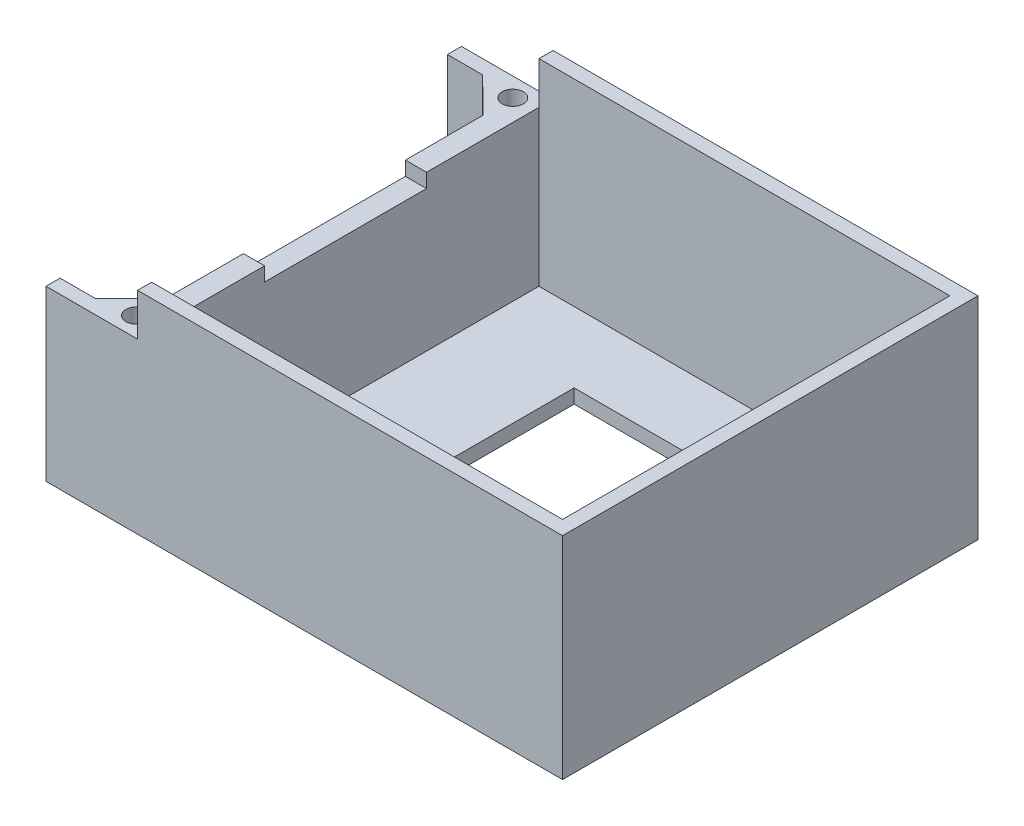
from build123d import *

# Parameters (mm, degrees)
SKETCH1_W           = 70
SKETCH1_H           = 55
BOSS_EXTRUDE1_DEPTH = 2
SKETCH2_W           = 73.35025282
SKETCH2_H           = 59
BOSS_EXTRUDE3_DEPTH = 2
BOSS_EXTRUDE4_DEPTH = 28
BOSS_EXTRUDE5_DEPTH = 22
SKETCH14_W          = 13
SKETCH14_H          = 2
CUT_EXTRUDE5_DEPTH  = 6
SKETCH15_R          = 1.5
CUT_EXTRUDE6_DEPTH  = 25
SKETCH16_R          = 2.25
CUT_EXTRUDE7_DEPTH  = 21
SKETCH17_W          = 3
SKETCH17_H          = 23
CUT_EXTRUDE8_DEPTH  = 2
SKETCH18_W          = 37
SKETCH18_H          = 35
CUT_EXTRUDE9_DEPTH  = 3
CUT_EXTRUDE12_DEPTH = 1


with BuildPart() as part:
    # Sketch1 → Boss-Extrude1 (new body)
    with BuildSketch(Plane(origin=(0, 0, 0), x_dir=(1, 0, 0), z_dir=(0, 1, 0))):
        with Locations((35, -27.5)):
            Rectangle(SKETCH1_W, SKETCH1_H)
    extrude(amount=BOSS_EXTRUDE1_DEPTH)

    # Sketch2 → Boss-Extrude3 (add)
    with BuildSketch(Plane(origin=(0, 0, 0), x_dir=(1, 0, 0), z_dir=(0, 1, 0))):
        with Locations((35.32487359, -27.5)):
            Rectangle(SKETCH2_W, SKETCH2_H)
    extrude(amount=BOSS_EXTRUDE3_DEPTH)

    # Sketch3 → Boss-Extrude4 (add)
    with BuildSketch(Plane(origin=(0, 2, 0), x_dir=(1, 0, 0), z_dir=(0, 1, 0))):
        Polygon((-1.35025282, 2), (72, 2), (72, -57), (-1.35025282, -57), (-1.35025282, -55), (70, -55), (70, 0), (-1.35025282, 0), align=None)
    extrude(amount=BOSS_EXTRUDE4_DEPTH)

    # Sketch5 → Boss-Extrude5 (add)
    with BuildSketch(Plane(origin=(0, 2, 0), x_dir=(1, 0, 0), z_dir=(0, 1, 0))):
        Polygon((11.64974718, 0), (8.64974718, 0), (8.64974718, -4.927247976), (8.64974718, -49.926173774), (8.64974718, -55), (11.64974718, -55), align=None)
        Polygon((8.64974718, -4.927247976), (8.64974718, 0), (3.64974718, 0), align=None)
        Polygon((8.64974718, -55), (8.64974718, -49.926173774), (3.64974718, -55), align=None)
    extrude(amount=BOSS_EXTRUDE5_DEPTH)

    # Sketch14 → Cut-Extrude5 (cut)
    with BuildSketch(Plane(origin=(0, 30, 0), x_dir=(1, 0, 0), z_dir=(0, 1, 0))):
        with Locations((5.14974718, 1)):
            Rectangle(SKETCH14_W, SKETCH14_H)
        with Locations((5.14974718, -56)):
            Rectangle(SKETCH14_W, SKETCH14_H)
    extrude(amount=-CUT_EXTRUDE5_DEPTH, mode=Mode.SUBTRACT)

    # Sketch15 → Cut-Extrude6 (cut, through all)
    with BuildSketch(Plane(origin=(0, 24, 0), x_dir=(1, 0, 0), z_dir=(0, 1, 0))):
        with Locations((8.61107216, -0.677247976)):
            Circle(SKETCH15_R)
        with Locations((8.673539748, -54.176107175)):
            Circle(SKETCH15_R)
    extrude(amount=-CUT_EXTRUDE6_DEPTH, mode=Mode.SUBTRACT)

    # Sketch16 → Cut-Extrude7 (cut)
    with BuildSketch(Plane.XZ):
        with Locations((8.673539748, 54.176107175)):
            Circle(SKETCH16_R)
        with Locations((8.61107216, 0.677247976)):
            Circle(SKETCH16_R)
    extrude(amount=-CUT_EXTRUDE7_DEPTH, mode=Mode.SUBTRACT)

    # Sketch17 → Cut-Extrude8 (cut)
    with BuildSketch(Plane(origin=(0, 24, 0), x_dir=(1, 0, 0), z_dir=(0, 1, 0))):
        with Locations((10.14974718, -27.463355437)):
            Rectangle(SKETCH17_W, SKETCH17_H)
    extrude(amount=-CUT_EXTRUDE8_DEPTH, mode=Mode.SUBTRACT)

    # Sketch18 → Cut-Extrude9 (cut, through all)
    with BuildSketch(Plane(origin=(0, 2, 0), x_dir=(1, 0, 0), z_dir=(0, 1, 0))):
        with Locations((45.14974718, -27.5)):
            Rectangle(SKETCH18_W, SKETCH18_H)
    extrude(amount=-CUT_EXTRUDE9_DEPTH, mode=Mode.SUBTRACT)

    # Sketch19 → Cut-Extrude12 (cut)
    with BuildSketch(Plane.XZ):
        Polygon((20.14974718, 39.144230769), (20.14974718, 38.495693109), (17.91527202, 37.977564103), (20.14974718, 37.383713942), (20.14974718, 36.773036859), (17.91527202, 36.182692308), (20.14974718, 35.665965545), (20.14974718, 35.016025641), (16.64974718, 35.825821314), (16.64974718, 36.482071314), (18.912267212, 37.080128205), (16.64974718, 37.681690705), (16.64974718, 38.333032853), align=None)
        with BuildLine():
            Line((20.14974718, 34.455128205), (20.14974718, 33.75400641))
            add(Edge.make_bspline(
                [(20.14974718, 33.75400641), (20.149542123, 33.708196022), (20.149146525, 33.61981818), (20.144349373, 33.492370061), (20.135752583, 33.37479293), (20.125128312, 33.267113803), (20.110233496, 33.169376952), (20.093157755, 33.081459982), (20.072354534, 33.003344649), (20.047661399, 32.934150086), (20.018549157, 32.872050201), (19.987542541, 32.81328368), (19.950537239, 32.759178654), (19.911521525, 32.707004279), (19.866768242, 32.659743453), (19.819255786, 32.614447763), (19.767099854, 32.573035606), (19.710931777, 32.535315092), (19.651789302, 32.501096774), (19.5895667, 32.471201362), (19.52416551, 32.446951878), (19.456008804, 32.426609576), (19.385099551, 32.410270441), (19.311001654, 32.399394593), (19.234232492, 32.39200717), (19.181983351, 32.391355332), (19.155556475, 32.391025641)],
                knots=[0, 0, 0, 0, 0.000137427, 0.000265126, 0.000382515, 0.000491069, 0.000589631, 0.000679006, 0.000759623, 0.000831924, 0.00089906, 0.000965255, 0.001030982, 0.001095489, 0.001160481, 0.001225953, 0.001292308, 0.00135998, 0.001428769, 0.001497134, 0.001566803, 0.001637786, 0.001710413, 0.00178488, 0.001862322, 0.001941576, 0.001941576, 0.001941576, 0.001941576], degree=3))
            add(Edge.make_bspline(
                [(19.155556475, 32.391025641), (19.126320204, 32.391500594), (19.068867338, 32.392433935), (18.984662923, 32.401652813), (18.904326984, 32.417246029), (18.827516374, 32.438121006), (18.754398954, 32.465349407), (18.685455686, 32.499476054), (18.619820312, 32.538511017), (18.558702004, 32.584598025), (18.501756932, 32.635507027), (18.448487103, 32.690388131), (18.400711862, 32.750485333), (18.357519866, 32.814961187), (18.318011188, 32.883282097), (18.28273718, 32.955761348), (18.252496611, 33.03291075), (18.236688241, 33.08664113), (18.228673462, 33.113882212)],
                knots=[0, 0, 0, 0, 8.7685e-05, 0.000172312, 0.000253715, 0.000332979, 0.000410854, 0.000487363, 0.000563476, 0.000639618, 0.000716591, 0.000792458, 0.000868777, 0.000946561, 0.00102509, 0.001105364, 0.001188171, 0.001273328, 0.001273328, 0.001273328, 0.001273328], degree=3))
            add(Edge.make_bspline(
                [(18.228673462, 33.113882212), (18.224209409, 33.131824432), (18.214538831, 33.170693061), (18.204720767, 33.235009965), (18.195693662, 33.309128443), (18.187935957, 33.39328817), (18.182662526, 33.487537666), (18.17854421, 33.591785672), (18.17554977, 33.706079432), (18.175443514, 33.785554793), (18.175388206, 33.826923077)],
                knots=[0, 0, 0, 0, 5.5442e-05, 0.000120105, 0.000194981, 0.000279468, 0.000373586, 0.000478137, 0.000592455, 0.000716555, 0.000716555, 0.000716555, 0.000716555], degree=3))
            Line((18.175388206, 33.826923077), (16.64974718, 33.826923077))
            Line((16.64974718, 33.826923077), (16.64974718, 34.455128205))
            Line((16.64974718, 34.455128205), (20.14974718, 34.455128205))
        make_face()
        with BuildLine():
            Line((18.803593334, 33.826923077), (18.803593334, 33.604667468))
            add(Edge.make_bspline(
                [(18.803593334, 33.604667468), (18.80384886, 33.564223938), (18.804319031, 33.489807241), (18.811152685, 33.38818883), (18.821544519, 33.306501474), (18.836565219, 33.242032689), (18.858946006, 33.191123441), (18.885893819, 33.147694371), (18.918325262, 33.109426393), (18.956560251, 33.076833898), (19.000070535, 33.050705551), (19.048587863, 33.032627347), (19.101009414, 33.020873497), (19.137494619, 33.01978866), (19.156257597, 33.019230769)],
                knots=[0, 0, 0, 0, 0.000121312, 0.000223216, 0.000305317, 0.000368234, 0.000420986, 0.000471375, 0.00052111, 0.000570845, 0.000621467, 0.000672509, 0.000725591, 0.00078179, 0.00078179, 0.00078179, 0.00078179], degree=3))
            add(Edge.make_bspline(
                [(19.156257597, 33.019230769), (19.172650318, 33.019783149), (19.20445614, 33.020854899), (19.250359829, 33.028728267), (19.293151536, 33.041276151), (19.33238436, 33.059457553), (19.367991637, 33.082961799), (19.39995934, 33.111618233), (19.428972084, 33.145059134), (19.444328973, 33.170877465), (19.452130994, 33.183994391)],
                knots=[0, 0, 0, 0, 4.9159e-05, 9.5379e-05, 0.000139299, 0.000182587, 0.00022459, 0.000266803, 0.000311063, 0.000356771, 0.000356771, 0.000356771, 0.000356771], degree=3))
            add(Edge.make_bspline(
                [(19.452130994, 33.183994391), (19.457750041, 33.195105185), (19.469646715, 33.218629011), (19.483477468, 33.258692369), (19.495145232, 33.304924871), (19.504829363, 33.357638641), (19.512345254, 33.416623387), (19.518093031, 33.481868585), (19.520404436, 33.553470251), (19.521152388, 33.603264925), (19.521542052, 33.629206731)],
                knots=[0, 0, 0, 0, 3.7318e-05, 7.901e-05, 0.000126794, 0.000180286, 0.000239683, 0.000305129, 0.000376698, 0.000454535, 0.000454535, 0.000454535, 0.000454535], degree=3))
            Line((19.521542052, 33.629206731), (19.521542052, 33.826923077))
            Line((19.521542052, 33.826923077), (18.803593334, 33.826923077))
        make_face(mode=Mode.SUBTRACT)
        with BuildLine():
            Line((19.542575706, 28.576923077), (19.102271219, 29.037560096))
            add(Edge.make_bspline(
                [(19.102271219, 29.037560096), (19.142726704, 29.076593241), (19.221877579, 29.152961315), (19.325610377, 29.27654181), (19.413404251, 29.403913276), (19.486428028, 29.534219209), (19.54213419, 29.669470568), (19.582184041, 29.807887228), (19.607122441, 29.95022164), (19.609890196, 30.046373814), (19.611285642, 30.094851763)],
                knots=[0, 0, 0, 0, 0.000168561, 0.000329789, 0.000483038, 0.000632107, 0.000777024, 0.00092081, 0.001063737, 0.001209074, 0.001209074, 0.001209074, 0.001209074], degree=3))
            add(Edge.make_bspline(
                [(19.611285642, 30.094851763), (19.610164965, 30.135332892), (19.607953433, 30.21521794), (19.591740723, 30.332510125), (19.564170304, 30.444706162), (19.526173159, 30.552190115), (19.47700687, 30.654645709), (19.416709491, 30.752287754), (19.345825593, 30.844875518), (19.264721932, 30.93118597), (19.176110088, 31.010139738), (19.081561461, 31.079900419), (18.981292658, 31.13833618), (18.876319127, 31.186293459), (18.766154998, 31.223650325), (18.65087444, 31.250327821), (18.53034016, 31.265757371), (18.448401855, 31.268060335), (18.406758398, 31.269230769)],
                knots=[0, 0, 0, 0, 0.000121424, 0.000239616, 0.000354399, 0.000467495, 0.000581016, 0.000694652, 0.000811184, 0.000930234, 0.001049421, 0.001166795, 0.001282115, 0.001396947, 0.001512462, 0.001630492, 0.001751372, 0.001876298, 0.001876298, 0.001876298, 0.001876298], degree=3))
            add(Edge.make_bspline(
                [(18.406758398, 31.269230769), (18.377529958, 31.268893893), (18.319920102, 31.268229903), (18.234701697, 31.260945919), (18.152009794, 31.249249659), (18.072015781, 31.232207179), (17.994410136, 31.211276597), (17.919213703, 31.18526421), (17.846471664, 31.154372008), (17.7763212, 31.119475192), (17.709571694, 31.080090759), (17.646207657, 31.036630374), (17.587035864, 30.988668157), (17.5300322, 30.938444904), (17.478600579, 30.882558409), (17.429759104, 30.823604911), (17.385168632, 30.760329104), (17.343619409, 30.694146803), (17.307529968, 30.624458473), (17.274838596, 30.553162415), (17.248288664, 30.47917561), (17.226886911, 30.403399433), (17.20868794, 30.326104534), (17.19748227, 30.246534939), (17.188996348, 30.165380404), (17.188472392, 30.110533561), (17.188208719, 30.082932692)],
                knots=[0, 0, 0, 0, 8.7665e-05, 0.00017279, 0.000256377, 0.000338057, 0.000417997, 0.000497376, 0.00057655, 0.000654938, 0.000732255, 0.00080888, 0.000885199, 0.00096066, 0.001036553, 0.001112769, 0.001190198, 0.001268605, 0.001347008, 0.001425458, 0.001503749, 0.001582528, 0.001661618, 0.001741736, 0.001823431, 0.00190619, 0.00190619, 0.00190619, 0.00190619], degree=3))
            add(Edge.make_bspline(
                [(17.188208719, 30.082932692), (17.189564899, 30.036117562), (17.192229441, 29.944138003), (17.21300601, 29.809133022), (17.247391579, 29.680321386), (17.287590945, 29.577236828), (17.327392071, 29.496616788), (17.364720254, 29.435794981), (17.405757115, 29.372482663), (17.453032098, 29.308080222), (17.505621623, 29.241883536), (17.564749786, 29.175104075), (17.62844876, 29.106019688), (17.673912857, 29.060763686), (17.697223142, 29.037560096)],
                knots=[0, 0, 0, 0, 0.0001404, 0.000275849, 0.000408674, 0.000539654, 0.000607068, 0.00067813, 0.000753582, 0.000833377, 0.00091769, 0.001007126, 0.00110089, 0.00119955, 0.00119955, 0.00119955, 0.00119955], degree=3))
            Line((17.697223142, 29.037560096), (17.228172661, 28.590945513))
            add(Edge.make_bspline(
                [(17.228172661, 28.590945513), (17.197862158, 28.622340114), (17.138702538, 28.683615661), (17.054701418, 28.776048129), (16.979216999, 28.868364242), (16.909509873, 28.958333946), (16.847609591, 29.047430655), (16.793458472, 29.135646245), (16.745672459, 29.221977464), (16.705107772, 29.308233231), (16.670444312, 29.395098252), (16.641210863, 29.484435561), (16.615692067, 29.576287845), (16.595610089, 29.671415828), (16.57926197, 29.769395057), (16.568459492, 29.870540376), (16.560968654, 29.974379199), (16.560327904, 30.044590853), (16.56000359, 30.080128205)],
                knots=[0, 0, 0, 0, 0.000130917, 0.000255521, 0.000374557, 0.000488566, 0.000596896, 0.00069983, 0.000798983, 0.000892761, 0.00098559, 0.001079375, 0.001174627, 0.001271438, 0.001370911, 0.001472494, 0.001576496, 0.001683088, 0.001683088, 0.001683088, 0.001683088], degree=3))
            add(Edge.make_bspline(
                [(16.56000359, 30.080128205), (16.561670526, 30.145403403), (16.564932256, 30.27312882), (16.58901627, 30.460325135), (16.629659271, 30.638304143), (16.686358799, 30.807385646), (16.759982834, 30.967052184), (16.849317141, 31.117804474), (16.955209598, 31.259391466), (17.076082507, 31.390594819), (17.209604572, 31.50923731), (17.352915702, 31.614222078), (17.507045051, 31.700683527), (17.668691069, 31.774041622), (17.840380907, 31.829012371), (18.02056315, 31.869026231), (18.210011021, 31.893374456), (18.339378103, 31.896064141), (18.405356154, 31.897435897)],
                knots=[0, 0, 0, 0, 0.000195794, 0.000383114, 0.000565099, 0.000742694, 0.00091712, 0.001091592, 0.001267434, 0.00144656, 0.001625835, 0.00180254, 0.001978381, 0.00215507, 0.00233422, 0.002518103, 0.002708205, 0.002906072, 0.002906072, 0.002906072, 0.002906072], degree=3))
            add(Edge.make_bspline(
                [(18.405356154, 31.897435897), (18.448383588, 31.896830993), (18.533653444, 31.895632221), (18.659376686, 31.884032958), (18.781578083, 31.865788864), (18.899881715, 31.840701367), (19.014946822, 31.80833737), (19.12601566, 31.768561782), (19.233548472, 31.721198875), (19.336857688, 31.666457655), (19.436515895, 31.605851736), (19.530785196, 31.537863059), (19.620679517, 31.464574723), (19.705028834, 31.384179923), (19.78416499, 31.29777341), (19.859058394, 31.205593212), (19.928305929, 31.106525364), (19.992247757, 31.001994424), (20.050656006, 30.893641593), (20.100876173, 30.782224585), (20.144052206, 30.66876806), (20.179183208, 30.553320651), (20.205610491, 30.435347352), (20.225572688, 30.315800031), (20.236740884, 30.193688203), (20.238568302, 30.111699731), (20.23949077, 30.0703125)],
                knots=[0, 0, 0, 0, 0.000129054, 0.000255754, 0.00037841, 0.000499558, 0.000618304, 0.00073673, 0.000853194, 0.000970489, 0.001087248, 0.001202821, 0.001318896, 0.001434944, 0.00155205, 0.001670199, 0.001790992, 0.001914365, 0.002037639, 0.002160014, 0.002280726, 0.002401606, 0.002521686, 0.002643174, 0.002764986, 0.002889156, 0.002889156, 0.002889156, 0.002889156], degree=3))
            add(Edge.make_bspline(
                [(20.23949077, 30.0703125), (20.238961872, 30.035005018), (20.237909575, 29.964757153), (20.229137534, 29.860146294), (20.215361133, 29.756372064), (20.194575478, 29.653806006), (20.169900279, 29.551714462), (20.137591509, 29.451439032), (20.101577297, 29.351397814), (20.058529659, 29.253159807), (20.011539275, 29.156587886), (19.958226977, 29.063944399), (19.901873545, 28.973673871), (19.839143736, 28.887776642), (19.772312877, 28.804643673), (19.701069165, 28.724709674), (19.624224756, 28.648676111), (19.569929646, 28.600961669), (19.542575706, 28.576923077)],
                knots=[0, 0, 0, 0, 0.000105907, 0.000210712, 0.000314726, 0.000419778, 0.000524527, 0.000629634, 0.000735659, 0.000843372, 0.000951235, 0.001057679, 0.001163882, 0.001270328, 0.001376541, 0.001483792, 0.001591374, 0.001700605, 0.001700605, 0.001700605, 0.001700605], degree=3))
        make_face()
        with BuildLine():
            Line((18.983080513, 26.198717949), (18.983080513, 26.826923077))
            add(Edge.make_bspline(
                [(18.983080513, 26.826923077), (19.030600908, 26.824209955), (19.123452906, 26.818908679), (19.258323405, 26.79782154), (19.385761197, 26.769565497), (19.505320488, 26.731854058), (19.616957836, 26.684467166), (19.721053818, 26.62862421), (19.817060367, 26.562898528), (19.904514484, 26.488688979), (19.982970379, 26.407255437), (20.052534305, 26.320288542), (20.109936705, 26.226458019), (20.157173567, 26.127478227), (20.194913624, 26.023366022), (20.220145907, 25.913136338), (20.237233455, 25.797743603), (20.238728684, 25.718747932), (20.23949077, 25.678485577)],
                knots=[0, 0, 0, 0, 0.000142716, 0.000278858, 0.000408976, 0.000534035, 0.000654361, 0.000772316, 0.000887831, 0.001002741, 0.001115793, 0.001226606, 0.001336154, 0.001444972, 0.001555191, 0.0016676, 0.00178371, 0.001904402, 0.001904402, 0.001904402, 0.001904402], degree=3))
            add(Edge.make_bspline(
                [(20.23949077, 25.678485577), (20.237946178, 25.629065192), (20.234930772, 25.53258502), (20.209285253, 25.392373456), (20.166137647, 25.261300555), (20.106450915, 25.139362264), (20.030273899, 25.028022336), (19.938649884, 24.928006063), (19.831897767, 24.83993814), (19.712194751, 24.765504226), (19.585246511, 24.704670111), (19.454511217, 24.661165951), (19.322713262, 24.632760624), (19.233988469, 24.629717101), (19.189911443, 24.628205128)],
                knots=[0, 0, 0, 0, 0.000148176, 0.000289274, 0.00042585, 0.000560994, 0.000695178, 0.000829168, 0.000966605, 0.001109, 0.001251067, 0.001387865, 0.001521654, 0.001653733, 0.001653733, 0.001653733, 0.001653733], degree=3))
            add(Edge.make_bspline(
                [(19.189911443, 24.628205128), (19.163249501, 24.628792326), (19.109585597, 24.629974211), (19.028378941, 24.638192012), (18.945660465, 24.650520334), (18.861501107, 24.669108458), (18.775877213, 24.692289296), (18.688532789, 24.720411304), (18.599962073, 24.754125373), (18.50917205, 24.792874452), (18.415852591, 24.839083557), (18.318668197, 24.892964315), (18.217332469, 24.955633127), (18.112585911, 25.027770306), (18.002158102, 25.106448144), (17.888892163, 25.195398079), (17.770932987, 25.292016325), (17.692134744, 25.36066405), (17.651650225, 25.395933494)],
                knots=[0, 0, 0, 0, 7.9977e-05, 0.000160974, 0.000244663, 0.00033075, 0.000419361, 0.000510712, 0.000605902, 0.000703579, 0.00080674, 0.00091815, 0.001036838, 0.001164018, 0.001299641, 0.001443533, 0.001595966, 0.001757034, 0.001757034, 0.001757034, 0.001757034], degree=3))
            Line((17.651650225, 25.395933494), (17.233080513, 25.761217949))
            Line((17.233080513, 25.761217949), (17.233080513, 24.583333333))
            Line((17.233080513, 24.583333333), (16.64974718, 24.583333333))
            Line((16.64974718, 24.583333333), (16.64974718, 26.916666667))
            Line((16.64974718, 26.916666667), (16.968056475, 26.916666667))
            Line((16.968056475, 26.916666667), (18.070921058, 25.880408654))
            add(Edge.make_bspline(
                [(18.070921058, 25.880408654), (18.103091961, 25.850406321), (18.165397458, 25.792300701), (18.25689971, 25.709622391), (18.343733162, 25.634805824), (18.426822417, 25.569402382), (18.503472396, 25.509979777), (18.575993427, 25.459187658), (18.643729892, 25.416561316), (18.725408239, 25.370284377), (18.822824202, 25.326336497), (18.935051386, 25.286011658), (19.042314727, 25.261430878), (19.112209826, 25.258037953), (19.14574077, 25.256410256)],
                knots=[0, 0, 0, 0, 0.000131967, 0.000255582, 0.000369957, 0.000475731, 0.00057277, 0.00066088, 0.000741219, 0.000812792, 0.000942363, 0.001061215, 0.001170268, 0.001270825, 0.001270825, 0.001270825, 0.001270825], degree=3))
            add(Edge.make_bspline(
                [(19.14574077, 25.256410256), (19.178189022, 25.257608242), (19.241062714, 25.259929531), (19.330240005, 25.28607446), (19.411593654, 25.325193734), (19.481417778, 25.381987503), (19.539295482, 25.45053613), (19.581707565, 25.530201026), (19.606635157, 25.61951948), (19.609705932, 25.68206651), (19.611285642, 25.714242788)],
                knots=[0, 0, 0, 0, 9.7062e-05, 0.000188073, 0.000276495, 0.000366282, 0.000455872, 0.000544007, 0.000635018, 0.00073144, 0.00073144, 0.00073144, 0.00073144], degree=3))
            add(Edge.make_bspline(
                [(19.611285642, 25.714242788), (19.610697822, 25.730862185), (19.609540604, 25.763580137), (19.601837319, 25.811672969), (19.588261083, 25.857436754), (19.570070838, 25.901380868), (19.545959538, 25.943036328), (19.516238519, 25.982298066), (19.481663059, 26.019579754), (19.442341273, 26.054710403), (19.398458147, 26.08668388), (19.350414466, 26.115082605), (19.29824005, 26.138563623), (19.242623682, 26.159237164), (19.182967997, 26.175181589), (19.119630028, 26.186791108), (19.052712816, 26.19561705), (19.006713526, 26.197665512), (18.983080513, 26.198717949)],
                knots=[0, 0, 0, 0, 4.9859e-05, 9.8155e-05, 0.000145635, 0.000192772, 0.000240515, 0.000289593, 0.000340201, 0.000392836, 0.000447528, 0.000502841, 0.000559939, 0.000618941, 0.00068068, 0.000744897, 0.000812032, 0.000882971, 0.000882971, 0.000882971, 0.000882971], degree=3))
        make_face()
        with BuildLine():
            add(Edge.make_bspline(
                [(20.23949077, 22.956029647), (20.239039416, 22.925621881), (20.238151934, 22.865832087), (20.22853773, 22.777773511), (20.2140176, 22.692946696), (20.193752021, 22.611029393), (20.166985337, 22.532576351), (20.134672072, 22.456954985), (20.096039638, 22.384801253), (20.051648379, 22.315948247), (20.002001905, 22.250075298), (19.944615112, 22.189373867), (19.882029997, 22.131494418), (19.813213487, 22.077396681), (19.737696521, 22.027686337), (19.65647952, 21.981435434), (19.568798001, 21.939240403), (19.474562599, 21.900543045), (19.372345013, 21.865924513), (19.260961345, 21.836847695), (19.140491437, 21.811569155), (19.010307681, 21.791661593), (18.870717167, 21.775367725), (18.721458686, 21.764721492), (18.562949936, 21.757315239), (18.45421033, 21.756717399), (18.398344936, 21.756410256)],
                knots=[0, 0, 0, 0, 9.1189e-05, 0.000179302, 0.000265406, 0.000349239, 0.000432161, 0.00051382, 0.000595686, 0.000677369, 0.000759404, 0.000842746, 0.000927593, 0.001014975, 0.001105008, 0.001198581, 0.001295163, 0.001396719, 0.00150403, 0.001618654, 0.00174186, 0.001873152, 0.002013604, 0.002163363, 0.002321972, 0.002489553, 0.002489553, 0.002489553, 0.002489553], degree=3))
            add(Edge.make_bspline(
                [(18.398344936, 21.756410256), (18.341780951, 21.75674452), (18.231878143, 21.757393989), (18.071914839, 21.764391606), (17.921589166, 21.776441737), (17.780916884, 21.791973113), (17.649971575, 21.813245826), (17.528416568, 21.83816245), (17.416287851, 21.867760217), (17.31386523, 21.90353097), (17.219406388, 21.941898086), (17.132201346, 21.984505669), (17.050683426, 22.028789926), (16.975988654, 22.077435317), (16.907952819, 22.129407998), (16.84595087, 22.183892052), (16.790836542, 22.242048459), (16.741471684, 22.303007487), (16.698261174, 22.368250416), (16.661137439, 22.437490262), (16.63045816, 22.511194232), (16.604014513, 22.588290116), (16.584989591, 22.670149435), (16.569906372, 22.755508255), (16.561567759, 22.845319899), (16.560533537, 22.906467687), (16.56000359, 22.937800481)],
                knots=[0, 0, 0, 0, 0.000169685, 0.000329694, 0.000480207, 0.000622052, 0.000754146, 0.000878038, 0.000994198, 0.001101735, 0.001203292, 0.001299874, 0.001392761, 0.001481438, 0.001566978, 0.001649425, 0.001728772, 0.001807063, 0.001884457, 0.001963189, 0.002042363, 0.002123732, 0.002207398, 0.002294193, 0.002383632, 0.002477624, 0.002477624, 0.002477624, 0.002477624], degree=3))
            add(Edge.make_bspline(
                [(16.56000359, 22.937800481), (16.56054604, 22.969131813), (16.561608692, 23.030509432), (16.569819081, 23.120572594), (16.5851807, 23.206576522), (16.603893784, 23.289197659), (16.630600748, 23.367710409), (16.661772489, 23.442688351), (16.699108259, 23.513758211), (16.742127058, 23.58096476), (16.791468106, 23.644064629), (16.846591901, 23.704042112), (16.907361914, 23.760763518), (16.974457934, 23.813366285), (17.046984631, 23.862711687), (17.125770082, 23.908285651), (17.210699895, 23.950058807), (17.301891254, 23.989345724), (17.401312261, 24.023456184), (17.50983075, 24.053916401), (17.628470993, 24.078450281), (17.756787193, 24.099939799), (17.895229019, 24.114368654), (18.043157859, 24.126708918), (18.201030194, 24.133613393), (18.309530042, 24.134274835), (18.365392212, 24.134615385)],
                knots=[0, 0, 0, 0, 9.3992e-05, 0.000184129, 0.000270924, 0.000355954, 0.000437988, 0.000519372, 0.000599343, 0.000678499, 0.000758439, 0.000839324, 0.000922666, 0.001007528, 0.001094842, 0.001185634, 0.001280327, 0.001378649, 0.001483306, 0.001595409, 0.001716557, 0.001846575, 0.001985555, 0.002133971, 0.002291879, 0.00245946, 0.00245946, 0.00245946, 0.00245946], degree=3))
            add(Edge.make_bspline(
                [(18.365392212, 24.134615385), (18.443008089, 24.134005926), (18.592768924, 24.132829968), (18.809160306, 24.118309448), (19.009028421, 24.096343852), (19.192614767, 24.066274638), (19.359560006, 24.025774684), (19.509816185, 23.976072469), (19.644870646, 23.919042509), (19.724890683, 23.870522927), (19.763429071, 23.847155449)],
                knots=[0, 0, 0, 0, 0.00023281, 0.000449211, 0.000650286, 0.000835861, 0.00100693, 0.001165013, 0.001310382, 0.001445437, 0.001445437, 0.001445437, 0.001445437], degree=3))
            add(Edge.make_bspline(
                [(19.763429071, 23.847155449), (19.801288123, 23.819979427), (19.875310028, 23.766844949), (19.972486954, 23.673937829), (20.055597419, 23.574121225), (20.12276056, 23.465344961), (20.175725419, 23.349329379), (20.213133901, 23.225078425), (20.234929827, 23.093050939), (20.237947752, 23.002385461), (20.23949077, 22.956029647)],
                knots=[0, 0, 0, 0, 0.000139664, 0.000273071, 0.000402072, 0.00052834, 0.000655415, 0.000783615, 0.000916514, 0.00105555, 0.00105555, 0.00105555, 0.00105555], degree=3))
        make_face()
        with BuildLine():
            add(Edge.make_bspline(
                [(19.611285642, 22.940604968), (19.609972737, 22.968088748), (19.607398746, 23.021971547), (19.585915258, 23.100039088), (19.552010972, 23.173323717), (19.512047606, 23.229422583), (19.473058559, 23.271222742), (19.438857955, 23.301517949), (19.398857627, 23.328650399), (19.354786564, 23.35482948), (19.3054319, 23.378121846), (19.25203848, 23.401282575), (19.192823753, 23.4201519), (19.128903709, 23.438735303), (19.058476289, 23.454981991), (18.980987624, 23.468696114), (18.895855041, 23.480522134), (18.803284908, 23.490507811), (18.702908666, 23.49685649), (18.594960014, 23.503000378), (18.479215552, 23.505236982), (18.399513154, 23.506010873), (18.358380994, 23.506410256)],
                knots=[0, 0, 0, 0, 8.233e-05, 0.000161411, 0.000241083, 0.000323566, 0.000366723, 0.000412431, 0.000460277, 0.000511502, 0.000566064, 0.00062388, 0.000685959, 0.000752315, 0.000823574, 0.000902652, 0.000988321, 0.001081388, 0.001181893, 0.001290012, 0.001405731, 0.001529136, 0.001529136, 0.001529136, 0.001529136], degree=3))
            add(Edge.make_bspline(
                [(18.358380994, 23.506410256), (18.305090909, 23.505770581), (18.202903219, 23.504543956), (18.055959133, 23.498094773), (17.922209389, 23.485242457), (17.800829354, 23.469048298), (17.692279596, 23.446987614), (17.596526417, 23.419518889), (17.512860906, 23.389057729), (17.442513453, 23.350865203), (17.382351942, 23.309945257), (17.330309227, 23.266269665), (17.286957013, 23.219076681), (17.250151848, 23.169776927), (17.222821859, 23.116542156), (17.202897418, 23.060463968), (17.190749014, 23.001417875), (17.189060379, 22.960993119), (17.188208719, 22.940604968)],
                knots=[0, 0, 0, 0, 0.00015988, 0.000306582, 0.00044109, 0.000562851, 0.000673817, 0.000773013, 0.000861557, 0.000940289, 0.001012436, 0.001079587, 0.001143589, 0.001204312, 0.001263581, 0.001322345, 0.001382433, 0.001443576, 0.001443576, 0.001443576, 0.001443576], degree=3))
            add(Edge.make_bspline(
                [(17.188208719, 22.940604968), (17.188790797, 22.920915715), (17.189930433, 22.882366605), (17.201628649, 22.826153369), (17.220647407, 22.772994139), (17.247550775, 22.723049419), (17.281762524, 22.676140564), (17.323432995, 22.632496835), (17.372977546, 22.592447385), (17.40974693, 22.569114393), (17.428693494, 22.557091346)],
                knots=[0, 0, 0, 0, 5.8998e-05, 0.000115512, 0.000171399, 0.00022786, 0.000285078, 0.000345085, 0.000408376, 0.000475658, 0.000475658, 0.000475658, 0.000475658], degree=3))
            add(Edge.make_bspline(
                [(17.428693494, 22.557091346), (17.454582504, 22.542931862), (17.508869657, 22.513240572), (17.60049542, 22.478968893), (17.703703985, 22.449732526), (17.819329853, 22.426295859), (17.946909081, 22.407732446), (18.086536489, 22.393540713), (18.238412218, 22.386332254), (18.343650968, 22.385202521), (18.398344936, 22.384615385)],
                knots=[0, 0, 0, 0, 8.843e-05, 0.000185431, 0.00029262, 0.000410049, 0.00053905, 0.000679276, 0.000830915, 0.000995001, 0.000995001, 0.000995001, 0.000995001], degree=3))
            add(Edge.make_bspline(
                [(18.398344936, 22.384615385), (18.453511978, 22.38484623), (18.559699117, 22.385290568), (18.712143239, 22.393442899), (18.851375666, 22.404795625), (18.977085455, 22.421401442), (19.089578072, 22.442767671), (19.18884522, 22.469102173), (19.275085513, 22.500146897), (19.348203595, 22.536967577), (19.410365933, 22.577731952), (19.463622739, 22.621060095), (19.509472694, 22.66702693), (19.546636031, 22.71612773), (19.576256157, 22.76803482), (19.596441646, 22.823028262), (19.60885908, 22.880925114), (19.61046587, 22.920443174), (19.611285642, 22.940604968)],
                knots=[0, 0, 0, 0, 0.000165478, 0.000318517, 0.00045785, 0.000584474, 0.000698739, 0.000801125, 0.000892295, 0.000973192, 0.001046115, 0.001114882, 0.001178838, 0.001240397, 0.001299099, 0.001357444, 0.001415472, 0.001475916, 0.001475916, 0.001475916, 0.001475916], degree=3))
        make_face(mode=Mode.SUBTRACT)
        with BuildLine():
            Line((18.983080513, 20.724358974), (18.983080513, 21.352564103))
            add(Edge.make_bspline(
                [(18.983080513, 21.352564103), (19.030600908, 21.349850981), (19.123452906, 21.344549704), (19.258323405, 21.323462565), (19.385761197, 21.295206523), (19.505320488, 21.257495083), (19.616957836, 21.210108192), (19.721053818, 21.154265235), (19.817060367, 21.088539553), (19.904514484, 21.014330004), (19.982970379, 20.932896462), (20.052534305, 20.845929567), (20.109936705, 20.752099044), (20.157173567, 20.653119253), (20.194913624, 20.549007048), (20.220145907, 20.438777363), (20.237233455, 20.323384629), (20.238728684, 20.244388958), (20.23949077, 20.204126603)],
                knots=[0, 0, 0, 0, 0.000142716, 0.000278858, 0.000408976, 0.000534035, 0.000654361, 0.000772316, 0.000887831, 0.001002741, 0.001115793, 0.001226606, 0.001336154, 0.001444972, 0.001555191, 0.0016676, 0.00178371, 0.001904402, 0.001904402, 0.001904402, 0.001904402], degree=3))
            add(Edge.make_bspline(
                [(20.23949077, 20.204126603), (20.237946178, 20.154706218), (20.234930772, 20.058226046), (20.209285253, 19.918014481), (20.166137647, 19.786941581), (20.106450915, 19.665003289), (20.030273899, 19.553663362), (19.938649884, 19.453647089), (19.831897767, 19.365579165), (19.712194751, 19.291145252), (19.585246511, 19.230311136), (19.454511217, 19.186806977), (19.322713262, 19.158401649), (19.233988469, 19.155358126), (19.189911443, 19.153846154)],
                knots=[0, 0, 0, 0, 0.000148176, 0.000289274, 0.00042585, 0.000560994, 0.000695178, 0.000829168, 0.000966605, 0.001109, 0.001251067, 0.001387865, 0.001521654, 0.001653733, 0.001653733, 0.001653733, 0.001653733], degree=3))
            add(Edge.make_bspline(
                [(19.189911443, 19.153846154), (19.163249501, 19.154433352), (19.109585597, 19.155615236), (19.028378941, 19.163833038), (18.945660465, 19.176161359), (18.861501107, 19.194749484), (18.775877213, 19.217930322), (18.688532789, 19.246052329), (18.599962073, 19.279766398), (18.50917205, 19.318515478), (18.415852591, 19.364724583), (18.318668197, 19.418605341), (18.217332469, 19.481274153), (18.112585911, 19.553411332), (18.002158102, 19.63208917), (17.888892163, 19.721039105), (17.770932987, 19.81765735), (17.692134744, 19.886305076), (17.651650225, 19.921574519)],
                knots=[0, 0, 0, 0, 7.9977e-05, 0.000160974, 0.000244663, 0.00033075, 0.000419361, 0.000510712, 0.000605902, 0.000703579, 0.00080674, 0.00091815, 0.001036838, 0.001164018, 0.001299641, 0.001443533, 0.001595966, 0.001757034, 0.001757034, 0.001757034, 0.001757034], degree=3))
            Line((17.651650225, 19.921574519), (17.233080513, 20.286858974))
            Line((17.233080513, 20.286858974), (17.233080513, 19.108974359))
            Line((17.233080513, 19.108974359), (16.64974718, 19.108974359))
            Line((16.64974718, 19.108974359), (16.64974718, 21.442307692))
            Line((16.64974718, 21.442307692), (16.968056475, 21.442307692))
            Line((16.968056475, 21.442307692), (18.070921058, 20.406049679))
            add(Edge.make_bspline(
                [(18.070921058, 20.406049679), (18.103091961, 20.376047347), (18.165397458, 20.317941726), (18.25689971, 20.235263417), (18.343733162, 20.160446849), (18.426822417, 20.095043407), (18.503472396, 20.035620802), (18.575993427, 19.984828683), (18.643729892, 19.942202342), (18.725408239, 19.895925403), (18.822824202, 19.851977523), (18.935051386, 19.811652683), (19.042314727, 19.787071903), (19.112209826, 19.783678978), (19.14574077, 19.782051282)],
                knots=[0, 0, 0, 0, 0.000131967, 0.000255582, 0.000369957, 0.000475731, 0.00057277, 0.00066088, 0.000741219, 0.000812792, 0.000942363, 0.001061215, 0.001170268, 0.001270825, 0.001270825, 0.001270825, 0.001270825], degree=3))
            add(Edge.make_bspline(
                [(19.14574077, 19.782051282), (19.178189022, 19.783249267), (19.241062714, 19.785570556), (19.330240005, 19.811715485), (19.411593654, 19.850834759), (19.481417778, 19.907628528), (19.539295482, 19.976177156), (19.581707565, 20.055842051), (19.606635157, 20.145160506), (19.609705932, 20.207707536), (19.611285642, 20.239883814)],
                knots=[0, 0, 0, 0, 9.7062e-05, 0.000188073, 0.000276495, 0.000366282, 0.000455872, 0.000544007, 0.000635018, 0.00073144, 0.00073144, 0.00073144, 0.00073144], degree=3))
            add(Edge.make_bspline(
                [(19.611285642, 20.239883814), (19.610697822, 20.256503211), (19.609540604, 20.289221163), (19.601837319, 20.337313995), (19.588261083, 20.38307778), (19.570070838, 20.427021894), (19.545959538, 20.468677354), (19.516238519, 20.507939092), (19.481663059, 20.54522078), (19.442341273, 20.580351429), (19.398458147, 20.612324905), (19.350414466, 20.64072363), (19.29824005, 20.664204648), (19.242623682, 20.68487819), (19.182967997, 20.700822614), (19.119630028, 20.712432134), (19.052712816, 20.721258076), (19.006713526, 20.723306538), (18.983080513, 20.724358974)],
                knots=[0, 0, 0, 0, 4.9859e-05, 9.8155e-05, 0.000145635, 0.000192772, 0.000240515, 0.000289593, 0.000340201, 0.000392836, 0.000447528, 0.000502841, 0.000559939, 0.000618941, 0.00068068, 0.000744897, 0.000812032, 0.000882971, 0.000882971, 0.000882971, 0.000882971], degree=3))
        make_face()
        with BuildLine():
            Line((19.297183078, 17.852564103), (19.297183078, 18.480769231))
            add(Edge.make_bspline(
                [(19.297183078, 18.480769231), (19.328584811, 18.476333864), (19.390145829, 18.46763862), (19.479270847, 18.446832066), (19.563812027, 18.421945181), (19.643501642, 18.390875177), (19.718481648, 18.354435117), (19.789009339, 18.312995556), (19.854781996, 18.266108516), (19.894403706, 18.230169103), (19.914170257, 18.212239583)],
                knots=[0, 0, 0, 0, 9.5097e-05, 0.000186431, 0.000274271, 0.000359292, 0.000442701, 0.000524107, 0.00060447, 0.000684475, 0.000684475, 0.000684475, 0.000684475], degree=3))
            add(Edge.make_bspline(
                [(19.914170257, 18.212239583), (19.940250789, 18.186378626), (19.991652777, 18.135409398), (20.057493045, 18.05023384), (20.11447332, 17.960954125), (20.159647694, 17.86577971), (20.196211116, 17.76619158), (20.220770849, 17.661397775), (20.237066449, 17.551826521), (20.238671623, 17.477057925), (20.23949077, 17.438902244)],
                knots=[0, 0, 0, 0, 0.000110078, 0.000216953, 0.000322189, 0.00042724, 0.000532366, 0.00063984, 0.000749603, 0.000863991, 0.000863991, 0.000863991, 0.000863991], degree=3))
            add(Edge.make_bspline(
                [(20.23949077, 17.438902244), (20.238689929, 17.404979879), (20.237115638, 17.338295347), (20.224478083, 17.240285863), (20.202313219, 17.146842023), (20.173333157, 17.056976096), (20.133900938, 16.97200972), (20.088128525, 16.890067602), (20.031986759, 16.813439209), (19.968552213, 16.741945244), (19.899941542, 16.676264403), (19.826602377, 16.619384506), (19.750493776, 16.570483838), (19.670983421, 16.530196155), (19.58793677, 16.499220403), (19.501833574, 16.477722311), (19.412863824, 16.463651289), (19.352392284, 16.462249447), (19.32172234, 16.461538462)],
                knots=[0, 0, 0, 0, 0.00010175, 0.000200019, 0.000295768, 0.000389553, 0.000482742, 0.000576315, 0.000670698, 0.000767061, 0.000862777, 0.0009552, 0.001045055, 0.001133791, 0.001222088, 0.001310343, 0.001399683, 0.001491626, 0.001491626, 0.001491626, 0.001491626], degree=3))
            add(Edge.make_bspline(
                [(19.32172234, 16.461538462), (19.283740169, 16.462997447), (19.208964951, 16.46586974), (19.099525863, 16.489438985), (18.994882566, 16.526331263), (18.896499175, 16.579625747), (18.804643435, 16.646257426), (18.722386359, 16.728012265), (18.648438269, 16.822561673), (18.608698556, 16.893541173), (18.588348943, 16.929887821)],
                knots=[0, 0, 0, 0, 0.000113843, 0.000224122, 0.000334341, 0.000445696, 0.000558585, 0.000673608, 0.000792534, 0.000917346, 0.000917346, 0.000917346, 0.000917346], degree=3))
            add(Edge.make_bspline(
                [(18.588348943, 16.929887821), (18.580158061, 16.904940039), (18.564063346, 16.855918768), (18.532364986, 16.786240925), (18.497723932, 16.719985259), (18.45748016, 16.658292667), (18.413260949, 16.600549544), (18.364688296, 16.547107896), (18.311868114, 16.497648424), (18.25450991, 16.452978532), (18.193531019, 16.413332258), (18.130340016, 16.377759768), (18.063978598, 16.348481625), (17.995204657, 16.323679393), (17.92340009, 16.304796386), (17.848843133, 16.291501062), (17.771703855, 16.283816038), (17.719442041, 16.282643941), (17.693016411, 16.282051282)],
                knots=[0, 0, 0, 0, 7.8716e-05, 0.000154674, 0.000229323, 0.000302834, 0.000375335, 0.000447305, 0.000519234, 0.000592164, 0.000665087, 0.000737272, 0.000809457, 0.000882418, 0.000956395, 0.001031899, 0.001109407, 0.001188683, 0.001188683, 0.001188683, 0.001188683], degree=3))
            add(Edge.make_bspline(
                [(17.693016411, 16.282051282), (17.654164393, 16.283149779), (17.577523571, 16.285316711), (17.465006878, 16.301857123), (17.357155551, 16.328424838), (17.253829808, 16.365748075), (17.155354244, 16.414629413), (17.061012488, 16.473617831), (16.97161894, 16.543772317), (16.887326346, 16.623059752), (16.810346423, 16.710829281), (16.743673142, 16.806089975), (16.686438549, 16.906623936), (16.639978234, 17.013100055), (16.604197346, 17.125472576), (16.578333568, 17.243493403), (16.562509607, 17.367657774), (16.56085077, 17.452409697), (16.56000359, 17.495693109)],
                knots=[0, 0, 0, 0, 0.000116521, 0.000229854, 0.000340385, 0.000449284, 0.000558716, 0.000669599, 0.000782499, 0.000899057, 0.001016326, 0.001132065, 0.001247292, 0.001362833, 0.001479905, 0.001600517, 0.001724874, 0.001854675, 0.001854675, 0.001854675, 0.001854675], degree=3))
            add(Edge.make_bspline(
                [(16.56000359, 17.495693109), (16.56089657, 17.53663865), (16.562642672, 17.616702238), (16.5777632, 17.73380973), (16.602136974, 17.845117886), (16.636552285, 17.950870847), (16.680892657, 18.050618376), (16.734412223, 18.144941603), (16.798750827, 18.232810808), (16.872390488, 18.314630529), (16.953871864, 18.389707119), (17.043859119, 18.455139303), (17.140385952, 18.51208255), (17.243659947, 18.560912676), (17.354602587, 18.59906471), (17.472223112, 18.629406011), (17.597030119, 18.65052963), (17.682892612, 18.656971814), (17.726670257, 18.66025641)],
                knots=[0, 0, 0, 0, 0.000122794, 0.000240108, 0.000353571, 0.000464208, 0.000573126, 0.000680526, 0.00078893, 0.000899152, 0.001010314, 0.001120678, 0.001232264, 0.001346118, 0.001462754, 0.00158366, 0.00171022, 0.00184187, 0.00184187, 0.00184187, 0.00184187], degree=3))
            Line((17.726670257, 18.66025641), (17.726670257, 18.032051282))
            add(Edge.make_bspline(
                [(17.726670257, 18.032051282), (17.704657963, 18.028070412), (17.661783249, 18.020316623), (17.599710193, 18.005193333), (17.542412929, 17.985485576), (17.4893822, 17.962698506), (17.439921731, 17.938085039), (17.395858219, 17.908346086), (17.355995159, 17.87566076), (17.308605514, 17.828495596), (17.259914632, 17.761069747), (17.217599939, 17.670022511), (17.192798331, 17.568741084), (17.189772611, 17.497935265), (17.188208719, 17.461338141)],
                knots=[0, 0, 0, 0, 6.7103e-05, 0.0001307, 0.000191452, 0.000248622, 0.000303811, 0.000356897, 0.000407708, 0.000458276, 0.000557145, 0.000655327, 0.000757866, 0.000867564, 0.000867564, 0.000867564, 0.000867564], degree=3))
            add(Edge.make_bspline(
                [(17.188208719, 17.461338141), (17.188541055, 17.441918131), (17.189192027, 17.403878676), (17.196431546, 17.348009179), (17.208304173, 17.294767266), (17.224678093, 17.243934085), (17.244609409, 17.195095987), (17.270965782, 17.149630921), (17.301407402, 17.10660556), (17.335274123, 17.066100081), (17.373329838, 17.02970116), (17.413572015, 16.997590957), (17.456251749, 16.97030217), (17.501275117, 16.949085032), (17.547627831, 16.930770855), (17.596566752, 16.919495178), (17.647147735, 16.911002127), (17.681760044, 16.910507463), (17.699326507, 16.91025641)],
                knots=[0, 0, 0, 0, 5.8231e-05, 0.000114062, 0.000168664, 0.000221658, 0.000274134, 0.000326573, 0.0003789, 0.000432134, 0.000484695, 0.000536597, 0.000586391, 0.00063625, 0.000685732, 0.000735556, 0.000786623, 0.000839249, 0.000839249, 0.000839249, 0.000839249], degree=3))
            add(Edge.make_bspline(
                [(17.699326507, 16.91025641), (17.718538714, 16.910921882), (17.756785816, 16.912246684), (17.81259942, 16.923070456), (17.866287608, 16.940163479), (17.917612624, 16.963907775), (17.966385295, 16.995615638), (18.013584148, 17.033030561), (18.056752566, 17.079100223), (18.099423239, 17.129644813), (18.136619197, 17.18825668), (18.170945601, 17.252081344), (18.198258821, 17.322796218), (18.222654585, 17.398675087), (18.240472872, 17.481153272), (18.253410686, 17.569718613), (18.263040883, 17.664228242), (18.264422493, 17.729374957), (18.265131795, 17.762820513)],
                knots=[0, 0, 0, 0, 5.7599e-05, 0.000114666, 0.000169877, 0.000226338, 0.000283714, 0.000344047, 0.000406522, 0.000472773, 0.000542199, 0.000614332, 0.000689846, 0.00076923, 0.000853263, 0.000942603, 0.001037692, 0.001138014, 0.001138014, 0.001138014, 0.001138014], degree=3))
            Line((18.265131795, 17.762820513), (18.848465129, 17.762820513))
            add(Edge.make_bspline(
                [(18.848465129, 17.762820513), (18.852014635, 17.721179644), (18.858655058, 17.643277825), (18.874131944, 17.535133669), (18.895033937, 17.44391313), (18.919813377, 17.367496342), (18.951807114, 17.304135822), (18.987978398, 17.249429597), (19.028477208, 17.201352098), (19.074227171, 17.161026451), (19.123688778, 17.129759609), (19.175134541, 17.106859616), (19.227861868, 17.091882495), (19.26390098, 17.090452268), (19.281758398, 17.08974359)],
                knots=[0, 0, 0, 0, 0.000125368, 0.000234538, 0.000327396, 0.000405884, 0.000474865, 0.00053962, 0.000602283, 0.000662896, 0.000721832, 0.000777074, 0.000831496, 0.000884947, 0.000884947, 0.000884947, 0.000884947], degree=3))
            add(Edge.make_bspline(
                [(19.281758398, 17.08974359), (19.304554889, 17.090943124), (19.349048813, 17.093284362), (19.412454568, 17.111948818), (19.469621414, 17.142974432), (19.519067985, 17.18612622), (19.560873841, 17.23849187), (19.590614593, 17.300280922), (19.60853371, 17.369422566), (19.610347556, 17.417990559), (19.611285642, 17.443108974)],
                knots=[0, 0, 0, 0, 6.8301e-05, 0.000133309, 0.000196371, 0.000262, 0.000328905, 0.000396008, 0.000466239, 0.000541468, 0.000541468, 0.000541468, 0.000541468], degree=3))
            add(Edge.make_bspline(
                [(19.611285642, 17.443108974), (19.610167759, 17.465872191), (19.607949538, 17.511041385), (19.591319636, 17.577065604), (19.563608256, 17.639694388), (19.524693613, 17.697321571), (19.478438841, 17.749805424), (19.42410057, 17.793812068), (19.363804167, 17.829636199), (19.319477165, 17.844891507), (19.297183078, 17.852564103)],
                knots=[0, 0, 0, 0, 6.824e-05, 0.000135409, 0.000202895, 0.000272705, 0.000343216, 0.000411983, 0.000481729, 0.000552303, 0.000552303, 0.000552303, 0.000552303], degree=3))
        make_face()
    extrude(amount=-CUT_EXTRUDE12_DEPTH, mode=Mode.SUBTRACT)


solid = part.part
